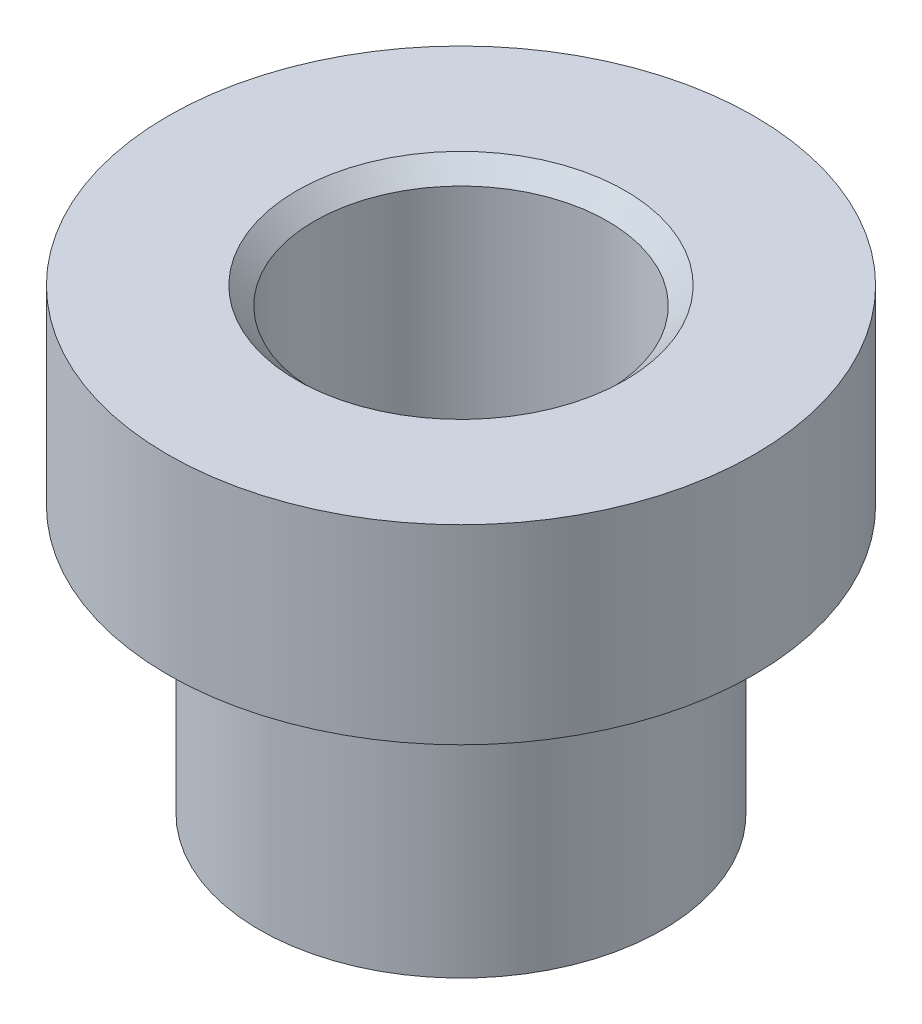
from build123d import *

# Parameters (mm, degrees)
CHAMFER1_SIZE = 0.762


with BuildPart() as part:
    # Sketch1 → Revolve1 (revolve)
    with BuildSketch(Plane.XY):
        Polygon((8.73125, 0), (12.7, 0), (12.7, 8.255), (6.35, 8.255), (6.35, -11.049), (0, -11.049), (0, -11.557), (8.73125, -11.557), align=None)
    revolve(axis=Axis((0, -11.049, 0), (0, -1, 0)))

    # Chamfer1
    chamfer1_edges = [part.edges().sort_by_distance(p)[0] for p in [
        (-6.35, 8.255, 0),
    ]]
    chamfer(chamfer1_edges, length=CHAMFER1_SIZE)


solid = part.part
